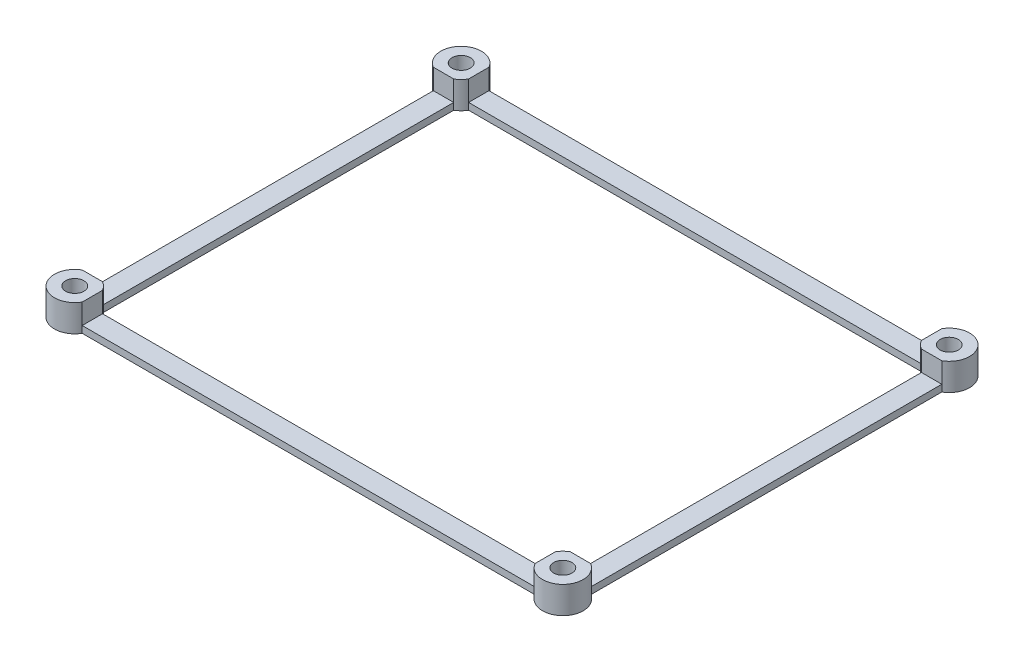
from build123d import *

# Parameters (mm, degrees)
SKETCH1_R           = 1.35
BOSS_EXTRUDE1_DEPTH = 4
SKETCH2_W           = 3
SKETCH2_H           = 51.803847578
SKETCH2_W_2         = 66.803847578
SKETCH2_H_2         = 3
CUT_EXTRUDE1_DEPTH  = 3


with BuildPart() as part:
    # Sketch1 → Boss-Extrude1 (new body)
    with BuildSketch(Plane(origin=(0, 0, 0), x_dir=(1, 0, 0), z_dir=(0, 1, 0))):
        with BuildLine():
            Line((-33.401923789, 30), (33.401923789, 30))
            ThreePointArc((33.401923789, 30), (38.121320344, 30.621320344), (37.5, 25.901923789))
            Line((37.5, 25.901923789), (37.5, -25.901923789))
            ThreePointArc((37.5, -25.901923789), (38.121320344, -30.621320344), (33.401923789, -30))
            Line((33.401923789, -30), (-33.401923789, -30))
            ThreePointArc((-33.401923789, -30), (-38.121320344, -30.621320344), (-37.5, -25.901923789))
            Line((-37.5, -25.901923789), (-37.5, 25.901923789))
            ThreePointArc((-37.5, 25.901923789), (-38.121320344, 30.621320344), (-33.401923789, 30))
        make_face()
        with Locations((36, 28.5)):
            Circle(SKETCH1_R, mode=Mode.SUBTRACT)
        with Locations((36, -28.5)):
            Circle(SKETCH1_R, mode=Mode.SUBTRACT)
        with Locations((-36, -28.5)):
            Circle(SKETCH1_R, mode=Mode.SUBTRACT)
        with Locations((-36, 28.5)):
            Circle(SKETCH1_R, mode=Mode.SUBTRACT)
        with BuildLine():
            Line((-33.401923789, 27), (33.401923789, 27))
            ThreePointArc((33.401923789, 27), (33.878679656, 26.378679656), (34.5, 25.901923789))
            Line((34.5, 25.901923789), (34.5, -25.901923789))
            ThreePointArc((34.5, -25.901923789), (33.878679656, -26.378679656), (33.401923789, -27))
            Line((33.401923789, -27), (-33.401923789, -27))
            ThreePointArc((-33.401923789, -27), (-33.878679656, -26.378679656), (-34.5, -25.901923789))
            Line((-34.5, -25.901923789), (-34.5, 25.901923789))
            ThreePointArc((-34.5, 25.901923789), (-33.878679656, 26.378679656), (-33.401923789, 27))
        make_face(mode=Mode.SUBTRACT)
    extrude(amount=BOSS_EXTRUDE1_DEPTH)

    # Sketch2 → Cut-Extrude1 (cut)
    with BuildSketch(Plane(origin=(0, 4, 0), x_dir=(1, 0, 0), z_dir=(0, 1, 0))):
        with Locations((-36, 0)):
            Rectangle(SKETCH2_W, SKETCH2_H)
        with Locations((0, -28.5)):
            Rectangle(SKETCH2_W_2, SKETCH2_H_2)
        with Locations((36, 0)):
            Rectangle(SKETCH2_W, SKETCH2_H)
        with Locations((0, 28.5)):
            Rectangle(SKETCH2_W_2, SKETCH2_H_2)
    extrude(amount=-CUT_EXTRUDE1_DEPTH, mode=Mode.SUBTRACT)


solid = part.part
